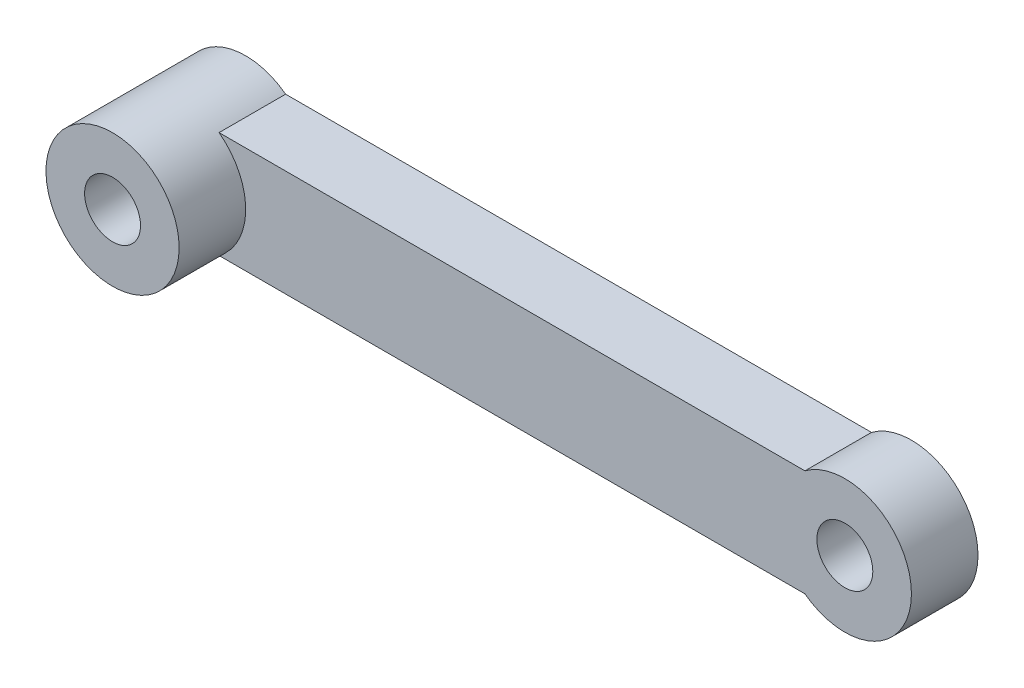
from build123d import *

# Parameters (mm, degrees)
SKETCH2_R           = 2.1
BOSS_EXTRUDE1_DEPTH = 5
SKETCH3_R           = 5
SKETCH3_R_2         = 2.1
BOSS_EXTRUDE2_DEPTH = 5


with BuildPart() as part:
    # Sketch2 → Boss-Extrude1 (new body)
    with BuildSketch(Plane.XY):
        with BuildLine():
            ThreePointArc((-40.021658011, 2.236067977), (-48.021658011, -1.763932023), (-40.021658011, -5.763932023))
            Line((-40.021658011, -5.763932023), (-40.021658011, 2.236067977))
        make_face()
        with Locations((-43.021658011, -1.763932023)):
            Circle(SKETCH2_R, mode=Mode.SUBTRACT)
        with BuildLine():
            Line((-40.021658011, 2.236067977), (-40.021658011, -5.763932023))
            ThreePointArc((-40.021658011, -5.763932023), (-38.549522056, -4), (-38.021658011, -1.763932023))
            ThreePointArc((-38.021658011, -1.763932023), (-38.549522056, 0.472135955), (-40.021658011, 2.236067977))
        make_face()
        with BuildLine():
            ThreePointArc((-38.021658011, -1.763932023), (-38.549522056, -4), (-40.021658011, -5.763932023))
            Line((-40.021658011, -5.763932023), (3.978341989, -5.763932023))
            ThreePointArc((3.978341989, -5.763932023), (1.978341989, -1.763932023), (3.978341989, 2.236067977))
            Line((3.978341989, 2.236067977), (-40.021658011, 2.236067977))
            ThreePointArc((-40.021658011, 2.236067977), (-38.549522056, 0.472135955), (-38.021658011, -1.763932023))
        make_face()
        with BuildLine():
            Line((3.978341989, 2.236067977), (3.978341989, -5.763932023))
            ThreePointArc((3.978341989, -5.763932023), (9.214409967, -6.236067977), (11.978341989, -1.763932023))
            ThreePointArc((11.978341989, -1.763932023), (9.214409967, 2.708203932), (3.978341989, 2.236067977))
        make_face()
        with Locations((6.978341989, -1.763932023)):
            Circle(SKETCH2_R, mode=Mode.SUBTRACT)
        with BuildLine():
            ThreePointArc((3.978341989, 2.236067977), (1.978341989, -1.763932023), (3.978341989, -5.763932023))
            Line((3.978341989, -5.763932023), (3.978341989, 2.236067977))
        make_face()
    extrude(amount=BOSS_EXTRUDE1_DEPTH)

    # Sketch3 → Boss-Extrude2 (add)
    with BuildSketch(Plane.XY.offset(5)):
        with Locations((-43.021658011, -1.763932023)):
            Circle(SKETCH3_R)
        with Locations((-43.021658011, -1.763932023)):
            Circle(SKETCH3_R_2, mode=Mode.SUBTRACT)
    extrude(amount=BOSS_EXTRUDE2_DEPTH)


solid = part.part
